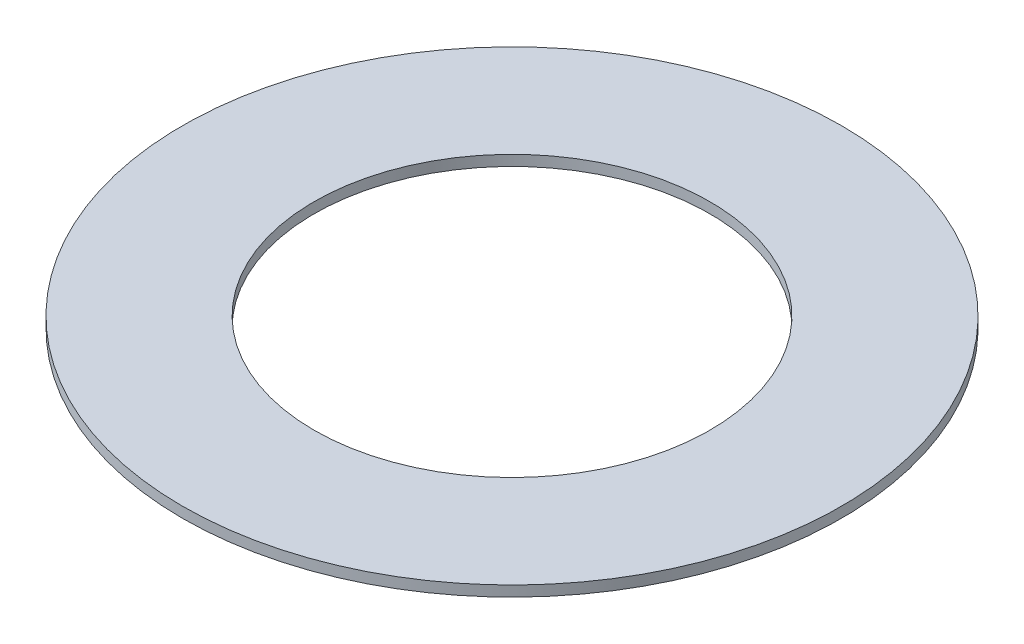
from build123d import *

# Parameters (mm, degrees)
SKETCH1_R           = 3.9751
SKETCH1_R_2         = 2.3876
BOSS_EXTRUDE1_DEPTH = 0.127


with BuildPart() as part:
    # Sketch1 → Boss-Extrude1 (new body)
    with BuildSketch(Plane(origin=(0, 0, 0), x_dir=(1, 0, 0), z_dir=(0, 1, 0))):
        Circle(SKETCH1_R)
        Circle(SKETCH1_R_2, mode=Mode.SUBTRACT)
    extrude(amount=BOSS_EXTRUDE1_DEPTH)


solid = part.part
